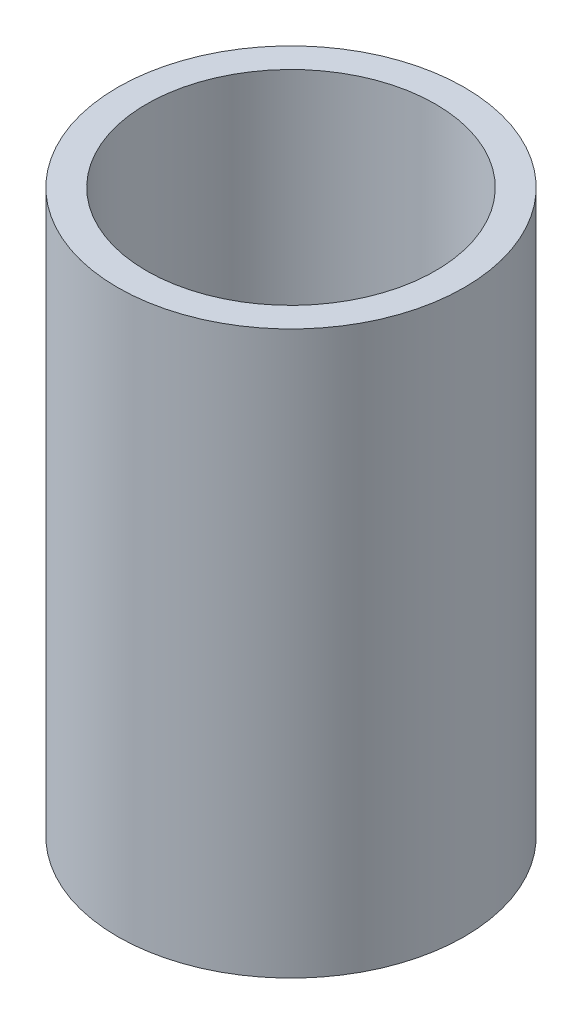
from build123d import *

# Parameters (mm, degrees)
SKETCH1_R      = 2.38125
SKETCH1_R_2    = 1.984375
EXTRUDE1_DEPTH = 7.7216


with BuildPart() as part:
    # Sketch1 → Extrude1 (new body)
    with BuildSketch(Plane(origin=(0, 0, 0), x_dir=(1, 0, 0), z_dir=(0, 1, 0))):
        Circle(SKETCH1_R)
        Circle(SKETCH1_R_2, mode=Mode.SUBTRACT)
    extrude(amount=EXTRUDE1_DEPTH)


solid = part.part
